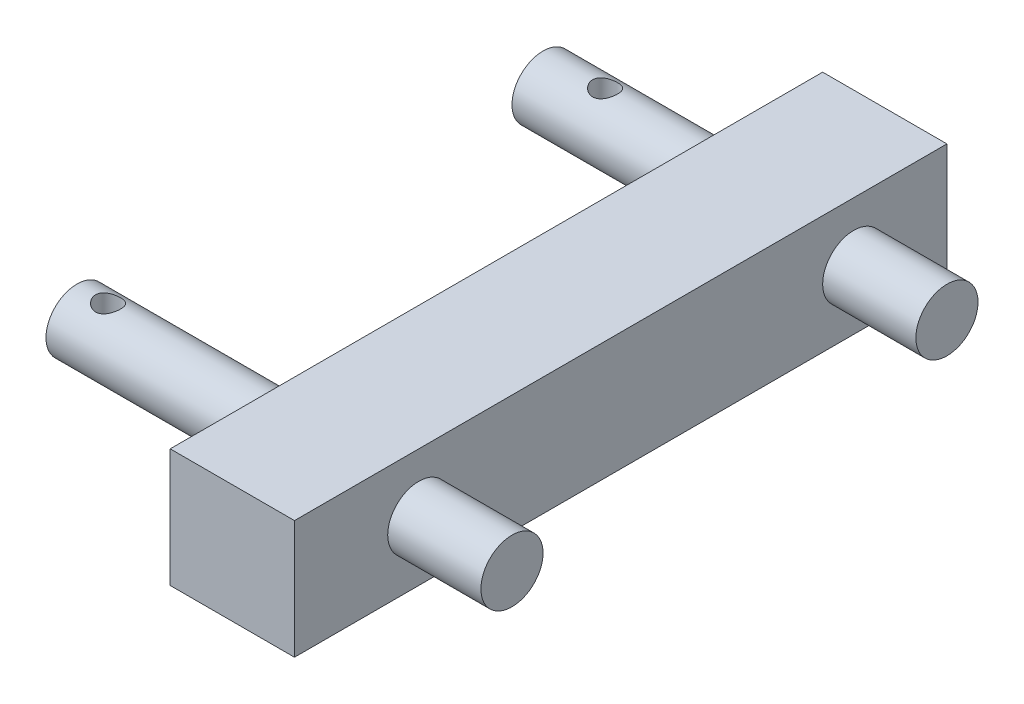
from build123d import *

# Parameters (mm, degrees)
SKETCH1_W           = 210
SKETCH1_H           = 38.1
BOSS_EXTRUDE1_DEPTH = 40
BOSS_EXTRUDE2_START = 30
SKETCH4_R           = 10
BOSS_EXTRUDE2_DEPTH = 140
CUT_EXTRUDE2_REACH  = 96.928
SKETCH5_R           = 4
BOSS_EXTRUDE3_START = 30
SKETCH2_R           = 10
BOSS_EXTRUDE3_DEPTH = 130
CUT_EXTRUDE3_REACH  = 96.928
SKETCH6_R           = 4


with BuildPart() as part:
    # Sketch1 → Boss-Extrude1 (new body)
    with BuildSketch(Plane(origin=(0, 0, 0), x_dir=(0, 0, -1), z_dir=(1, 0, 0))):
        with Locations((-45, 75.877536232)):
            Rectangle(SKETCH1_W, SKETCH1_H)
    extrude(amount=BOSS_EXTRUDE1_DEPTH)

    # Sketch4 → Boss-Extrude2 (add)
    with BuildSketch(Plane(origin=(40, 0, 0), x_dir=(0, 0, -1), z_dir=(1, 0, 0)).offset(BOSS_EXTRUDE2_START)):
        with Locations((-110, 75.877536232)):
            Circle(SKETCH4_R)
    extrude(amount=-BOSS_EXTRUDE2_DEPTH)

    # Sketch5 → Cut-Extrude2 (cut, up to next)
    with BuildSketch(Plane(origin=(0, 0, 0), x_dir=(1, 0, 0), z_dir=(0, 1, 0)), mode=Mode.PRIVATE) as cut_extrude2_sk1:
        with Locations((-60, -110)):
            Circle(SKETCH5_R)
    cut_extrude2_tool1 = extrude(cut_extrude2_sk1.sketch, amount=CUT_EXTRUDE2_REACH, mode=Mode.PRIVATE) & part.part
    add(cut_extrude2_tool1.solids().sort_by_distance((-60, 0, 110))[0], mode=Mode.SUBTRACT)

    # Sketch2 → Boss-Extrude3 (add)
    with BuildSketch(Plane(origin=(40, 0, 0), x_dir=(0, 0, -1), z_dir=(1, 0, 0)).offset(BOSS_EXTRUDE3_START)):
        with Locations((30, 75.827536232)):
            Circle(SKETCH2_R)
    extrude(amount=-BOSS_EXTRUDE3_DEPTH)

    # Sketch6 → Cut-Extrude3 (cut, up to next)
    with BuildSketch(Plane(origin=(0, 0, 0), x_dir=(1, 0, 0), z_dir=(0, 1, 0)), mode=Mode.PRIVATE) as cut_extrude3_sk1:
        with Locations((-40, 30)):
            Circle(SKETCH6_R)
    cut_extrude3_tool1 = extrude(cut_extrude3_sk1.sketch, amount=CUT_EXTRUDE3_REACH, mode=Mode.PRIVATE) & part.part
    add(cut_extrude3_tool1.solids().sort_by_distance((-40, 0, -30))[0], mode=Mode.SUBTRACT)


solid = part.part
